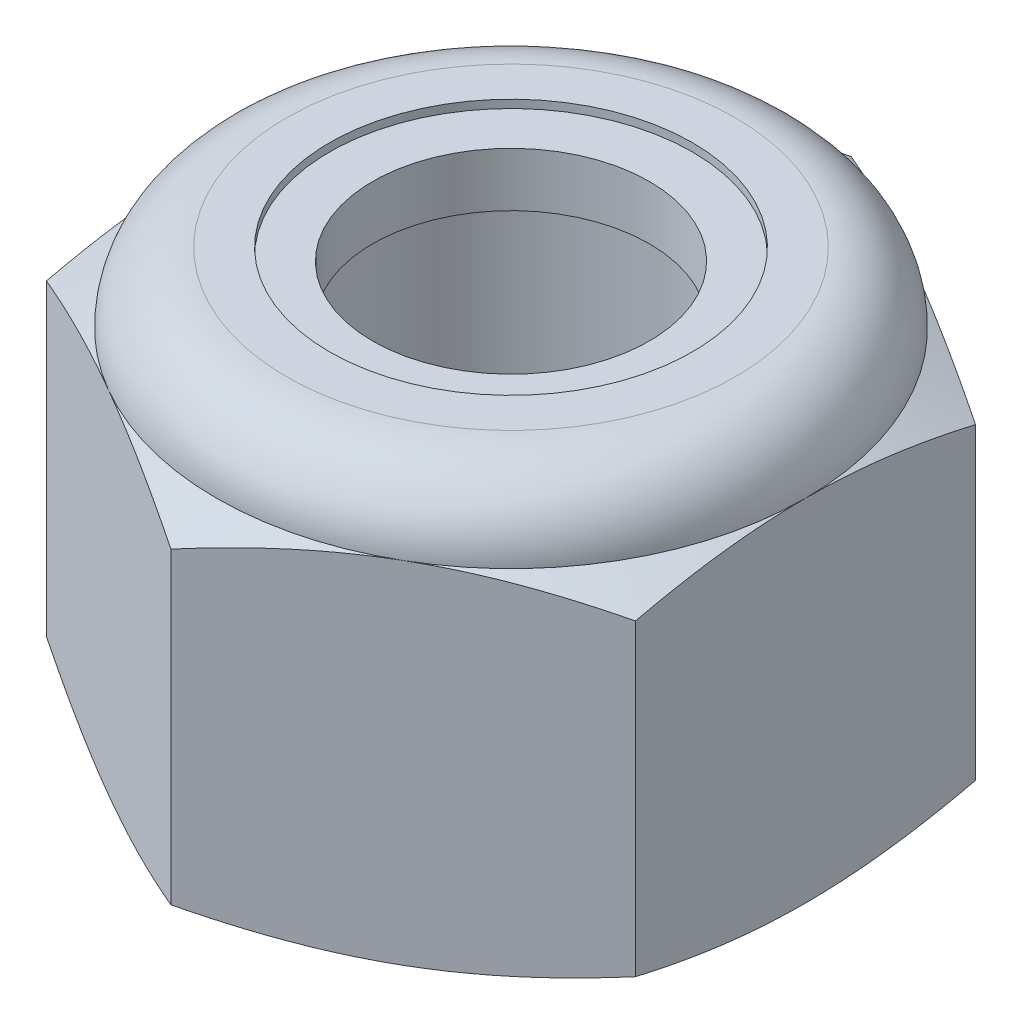
from build123d import *

# Parameters (mm, degrees)
EXTRUDE1_DEPTH = 7.9375
SKETCH2_W      = 3.175
SKETCH2_H      = 7.9375


with BuildPart() as part:
    # Sketch1 → Extrude1 (new body)
    with BuildSketch(Plane(origin=(0, 0, 0), x_dir=(1, 0, 0), z_dir=(0, 1, 0))):
        Polygon((0, 6.415804866), (-5.55625, 3.207902433), (-5.55625, -3.207902433), (0, -6.415804866), (5.55625, -3.207902433), (5.55625, 3.207902433), align=None)
    extrude(amount=EXTRUDE1_DEPTH)

    # Sketch4 → Cut-Revolve2 (revolve, cut)
    with BuildSketch(Plane(origin=(0, 0, 0), x_dir=(0, 0, -1), z_dir=(1, 0, 0))):
        Polygon((0, 7.9375), (3.175, 7.9375), (2.609908356, 7.673993439), (2.609908356, 0.263506561), (3.175, 0), (0, 0), align=None)
    revolve(axis=Axis((0, 7.9375, 0), (0, 1, 0)), mode=Mode.SUBTRACT)


with BuildPart() as body_2:
    # Sketch2 → Revolve1 (revolve)
    with BuildSketch(Plane(origin=(0, 0, 0), x_dir=(0, 0, -1), z_dir=(1, 0, 0))):
        with Locations((1.5875, 3.96875)):
            Rectangle(SKETCH2_W, SKETCH2_H)
    revolve(axis=Axis((0, -3.175, 0), (0, 1, 0)))


with BuildPart() as part_1:
    add(part.part)

    # Combine1: cut body 2
    add(body_2.part, mode=Mode.SUBTRACT)

    # Sketch5 → Cut-Revolve3 (revolve, cut)
    with BuildSketch(Plane(origin=(0, 0, 0), x_dir=(0, 0, -1), z_dir=(1, 0, 0))):
        with BuildLine():
            Line((0, 0), (5.55625, 0))
            Line((5.55625, 0), (6.415804866, 0.400817017))
            Line((6.415804866, 0.400817017), (6.415804866, 6.213766317))
            Line((6.415804866, 6.213766317), (5.55625, 6.614583333))
            ThreePointArc((5.55625, 6.614583333), (5.168776679, 7.550026679), (4.233333333, 7.9375))
            Line((4.233333333, 7.9375), (4.233333333, 9.2075))
            Line((4.233333333, 9.2075), (7.685804866, 9.2075))
            Line((7.685804866, 9.2075), (7.685804866, -1.27))
            Line((7.685804866, -1.27), (0, -1.27))
            Line((0, -1.27), (0, 0))
        make_face()
    revolve(axis=Axis((0, 0, 0), (0, 1, 0)), mode=Mode.SUBTRACT)

    # Sketch6 → Cut-Revolve4 (revolve, cut)
    with BuildSketch(Plane(origin=(0, 0, 0), x_dir=(0, 0, -1), z_dir=(1, 0, 0))):
        with BuildLine():
            Line((0, 6.614583333), (5.40385, 6.614583333))
            ThreePointArc((5.40385, 6.614583333), (5.061013606, 7.442263606), (4.233333333, 7.7851))
            Line((4.233333333, 7.7851), (3.421620845, 7.7851))
            Line((3.421620845, 7.7851), (3.421620845, 9.2075))
            Line((3.421620845, 9.2075), (0, 9.2075))
            Line((0, 9.2075), (0, 6.614583333))
        make_face()
    revolve(axis=Axis((0, 9.2075, 0), (0, 1, 0)), mode=Mode.SUBTRACT)


with BuildPart() as body_2_2:
    # Sketch7 → Revolve2 (revolve)
    with BuildSketch(Plane(origin=(0, 0, 0), x_dir=(0, 0, -1), z_dir=(1, 0, 0))):
        with BuildLine():
            Line((2.609908356, 6.690783333), (5.324993778, 6.690783333))
            ThreePointArc((5.324993778, 6.690783333), (4.979705237, 7.4148695), (4.233333333, 7.7089))
            Line((4.233333333, 7.7089), (2.609908356, 7.7089))
            Line((2.609908356, 7.7089), (2.609908356, 6.690783333))
        make_face()
    revolve(axis=Axis((0, 6.690783333, 0), (0, 1, 0)))


solid = Compound([part_1.part, body_2_2.part])
